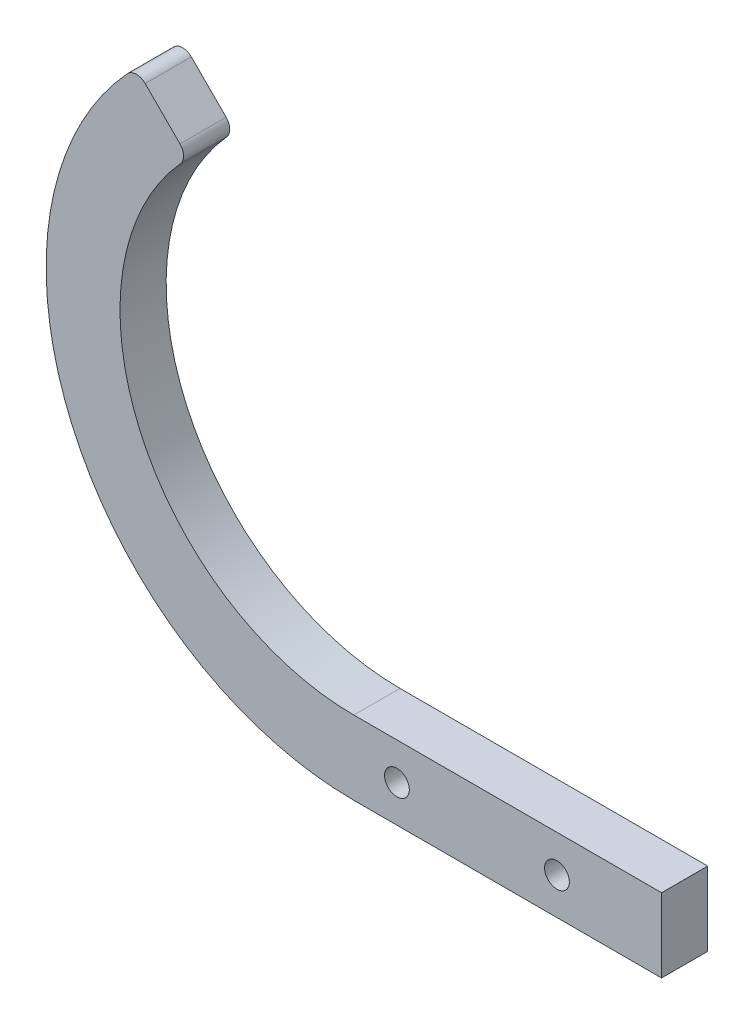
from build123d import *

# Parameters (mm, degrees)
BOSS_EXTRUDE1_DEPTH     = 9.525
F_1_4_20_TAPPED_HOLE1_D = 5.1054


with BuildPart() as part:
    # Sketch2 → Boss-Extrude1 (new body)
    with BuildSketch(Plane.XY):
        with BuildLine():
            Line((0, -63.5), (63.5, -63.5))
            Line((63.5, -63.5), (63.5, -48.26))
            Line((63.5, -48.26), (0, -48.26))
            ThreePointArc((0, -48.26), (-44.110630078, -19.577535956), (-35.788539013, 32.376041687))
            ThreePointArc((-35.788539013, 32.376041687), (-35.1329407, 34.143563747), (-35.876095105, 35.876095105))
            Line((-35.876095105, 35.876095105), (-43.067795393, 43.067795393))
            ThreePointArc((-43.067795393, 43.067795393), (-44.916774776, 43.811192654), (-46.733173559, 42.991400176))
            ThreePointArc((-46.733173559, 42.991400176), (-58.147243749, -25.517602639), (0, -63.5))
        make_face()
    extrude(amount=BOSS_EXTRUDE1_DEPTH)

    # 1/4-20 Tapped Hole1 (through all)
    with Locations(Plane.XY.offset(9.525)):
        with Locations((8.89, -55.88), (41.91, -55.88)):
            Hole(F_1_4_20_TAPPED_HOLE1_D / 2)


solid = part.part
